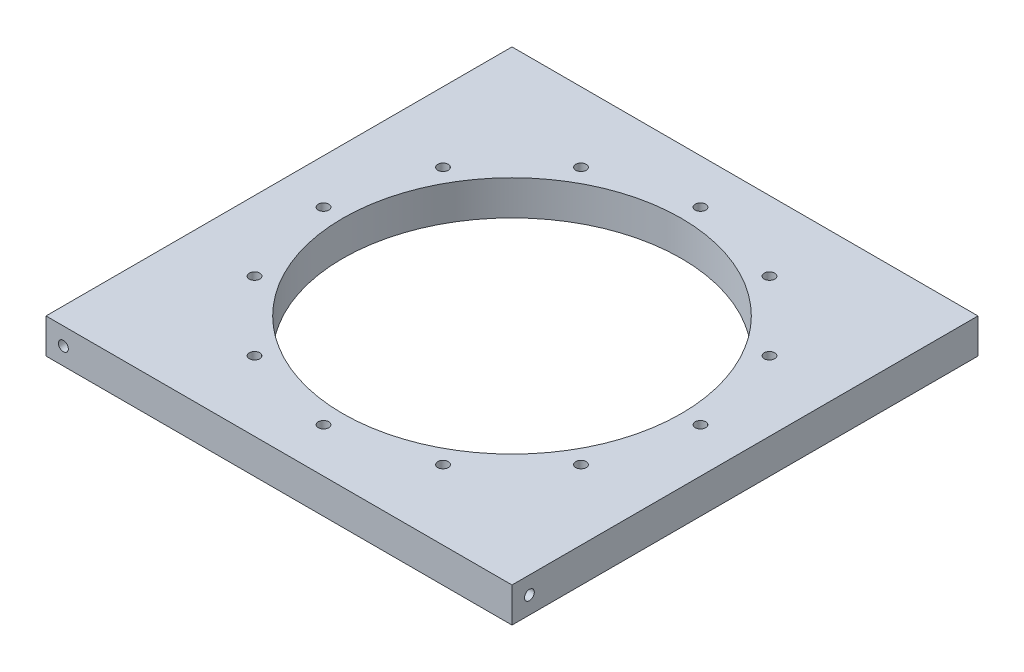
from build123d import *

# Parameters (mm, degrees)
SKETCH1_W           = 127.635
SKETCH1_H           = 127.635
BOSS_EXTRUDE1_DEPTH = 9.525
SKETCH5_R           = 46.355
CUT_EXTRUDE1_DEPTH  = 9.525
SKETCH11_R          = 1.4351
CUT_EXTRUDE3_DEPTH  = 10.525
CIRPATTERN1_COUNT   = 12
SKETCH6_R           = 1.35255
F_6_32_HOLE1_DEPTH  = 12.7
SKETCH7_R           = 1.35255
F_6_32_HOLE2_DEPTH  = 12.7
SKETCH8_R           = 1.35255
F_6_32_HOLE3_DEPTH  = 12.7
SKETCH9_R           = 1.35255
F_6_32_HOLE4_DEPTH  = 12.7


with BuildPart() as part:
    # Sketch1 → Boss-Extrude1 (new body)
    with BuildSketch(Plane(origin=(0, 0, 0), x_dir=(1, 0, 0), z_dir=(0, 1, 0))):
        with Locations((63.8175, 63.8175)):
            Rectangle(SKETCH1_W, SKETCH1_H)
    extrude(amount=BOSS_EXTRUDE1_DEPTH)

    # Sketch5 → Cut-Extrude1 (cut)
    with BuildSketch(Plane(origin=(0, 9.525, 0), x_dir=(1, 0, 0), z_dir=(0, 1, 0))):
        with Locations((63.8175, 63.8175)):
            Circle(SKETCH5_R)
    extrude(amount=-CUT_EXTRUDE1_DEPTH, mode=Mode.SUBTRACT)

    # Sketch11 → Cut-Extrude3 (cut, through all)
    with BuildSketch(Plane(origin=(0, 9.525, 0), x_dir=(1, 0, 0), z_dir=(0, 1, 0))):
        with Locations((63.8175, 115.443)):
            Circle(SKETCH11_R)
    cut_extrude3 = extrude(amount=-CUT_EXTRUDE3_DEPTH, mode=Mode.SUBTRACT)

    # CirPattern1: Cut-Extrude3 ×12 about axis
    cirpattern1_axis = Axis((63.8175, 0, -63.8175), (0, 1, 0))
    for i in range(1, CIRPATTERN1_COUNT):
        add(cut_extrude3.rotate(cirpattern1_axis, i * 360 / CIRPATTERN1_COUNT), mode=Mode.SUBTRACT)

    # Sketch6 → 6-32 hole1 (cut)
    with BuildSketch(Plane(origin=(127.635, 0, 0), x_dir=(0, 0, -1), z_dir=(1, 0, 0))):
        with Locations((4.7625, 4.7625)):
            Circle(SKETCH6_R)
    extrude(amount=-F_6_32_HOLE1_DEPTH, mode=Mode.SUBTRACT)

    # Sketch7 → 6-32 hole2 (cut)
    with BuildSketch(Plane(origin=(0, 0, -127.635), x_dir=(-1, 0, 0), z_dir=(0, 0, -1))):
        with Locations((-122.8725, 4.7625)):
            Circle(SKETCH7_R)
    extrude(amount=-F_6_32_HOLE2_DEPTH, mode=Mode.SUBTRACT)

    # Sketch8 → 6-32 hole3 (cut)
    with BuildSketch(Plane.ZY):
        with Locations((-122.8725, 4.7625)):
            Circle(SKETCH8_R)
    extrude(amount=-F_6_32_HOLE3_DEPTH, mode=Mode.SUBTRACT)

    # Sketch9 → 6-32 hole4 (cut)
    with BuildSketch(Plane.XY):
        with Locations((4.7625, 4.7625)):
            Circle(SKETCH9_R)
    extrude(amount=-F_6_32_HOLE4_DEPTH, mode=Mode.SUBTRACT)


solid = part.part
